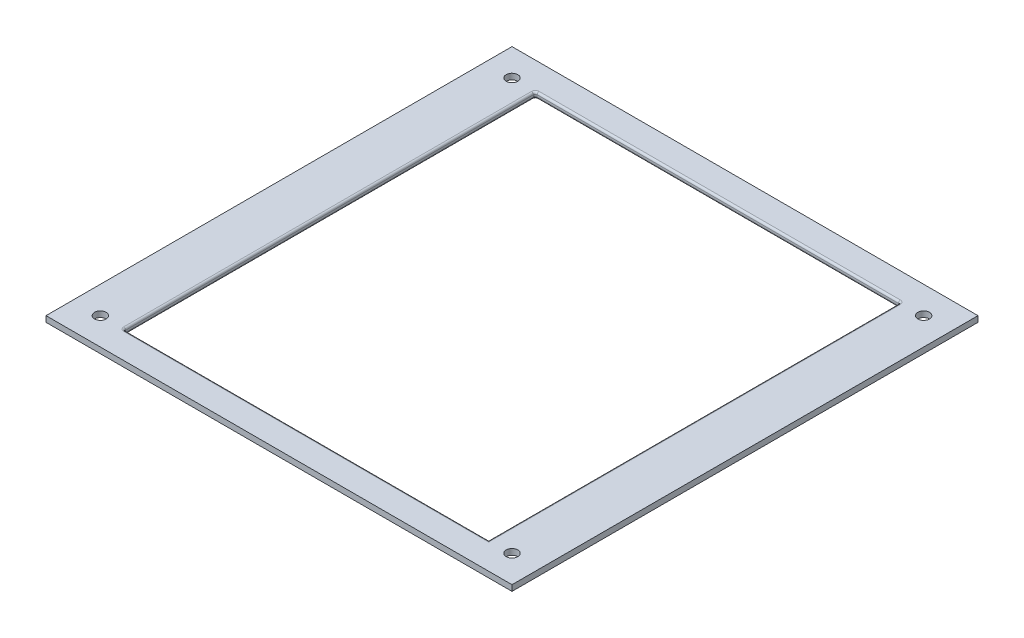
from build123d import *

# Parameters (mm, degrees)
SKETCH1_W           = 120
SKETCH1_H           = 120
BOSS_EXTRUDE1_DEPTH = 1.5
SKETCH4_R           = 2.5
CUT_EXTRUDE2_DEPTH  = 1.5
SKETCH7_R           = 1.5
CUT_EXTRUDE3_DEPTH  = 1.5
SKETCH8_W           = 94
SKETCH8_H           = 106
CUT_EXTRUDE4_DEPTH  = 1.5
FILLET1_R           = 0.5


with BuildPart() as part:
    # Sketch1 → Boss-Extrude1 (new body)
    with BuildSketch(Plane(origin=(0, 0, 0), x_dir=(1, 0, 0), z_dir=(0, 1, 0))):
        Rectangle(SKETCH1_W, SKETCH1_H)
    extrude(amount=BOSS_EXTRUDE1_DEPTH)

    # Sketch4 → Cut-Extrude2 (cut)
    with BuildSketch(Plane(origin=(0, 0, 0), x_dir=(1, 0, 0), z_dir=(0, 1, 0))):
        with Locations((-22.5, 0)):
            Circle(SKETCH4_R)
        with Locations((22.5, 0)):
            Circle(SKETCH4_R)
    extrude(amount=CUT_EXTRUDE2_DEPTH, mode=Mode.SUBTRACT)

    # Sketch7 → Cut-Extrude3 (cut)
    with BuildSketch(Plane(origin=(0, 0, 0), x_dir=(1, 0, 0), z_dir=(0, 1, 0))):
        with Locations((-53, 53)):
            Circle(SKETCH7_R)
        with Locations((53, 53)):
            Circle(SKETCH7_R)
        with Locations((-53, -53)):
            Circle(SKETCH7_R)
        with Locations((53, -53)):
            Circle(SKETCH7_R)
    extrude(amount=CUT_EXTRUDE3_DEPTH, mode=Mode.SUBTRACT)

    # Sketch8 → Cut-Extrude4 (cut)
    with BuildSketch(Plane(origin=(0, 0, 0), x_dir=(1, 0, 0), z_dir=(0, 1, 0))):
        Rectangle(SKETCH8_W, SKETCH8_H)
    extrude(amount=CUT_EXTRUDE4_DEPTH, mode=Mode.SUBTRACT)

    # Fillet1
    fillet1_edges = [part.edges().sort_by_distance(p)[0] for p in [
        (0, 1.5, -53),
        (47, 0.75, -53),
        (0, 0, -53),
        (47, 1.5, 0),
        (47, 0, 0),
        (0, 1.5, 53),
        (-47, 0.75, 53),
        (0, 0, 53),
        (-47, 1.5, 0),
        (-47, 0.75, -53),
        (-47, 0, 0),
    ]]
    fillet(fillet1_edges, radius=FILLET1_R)


solid = part.part
